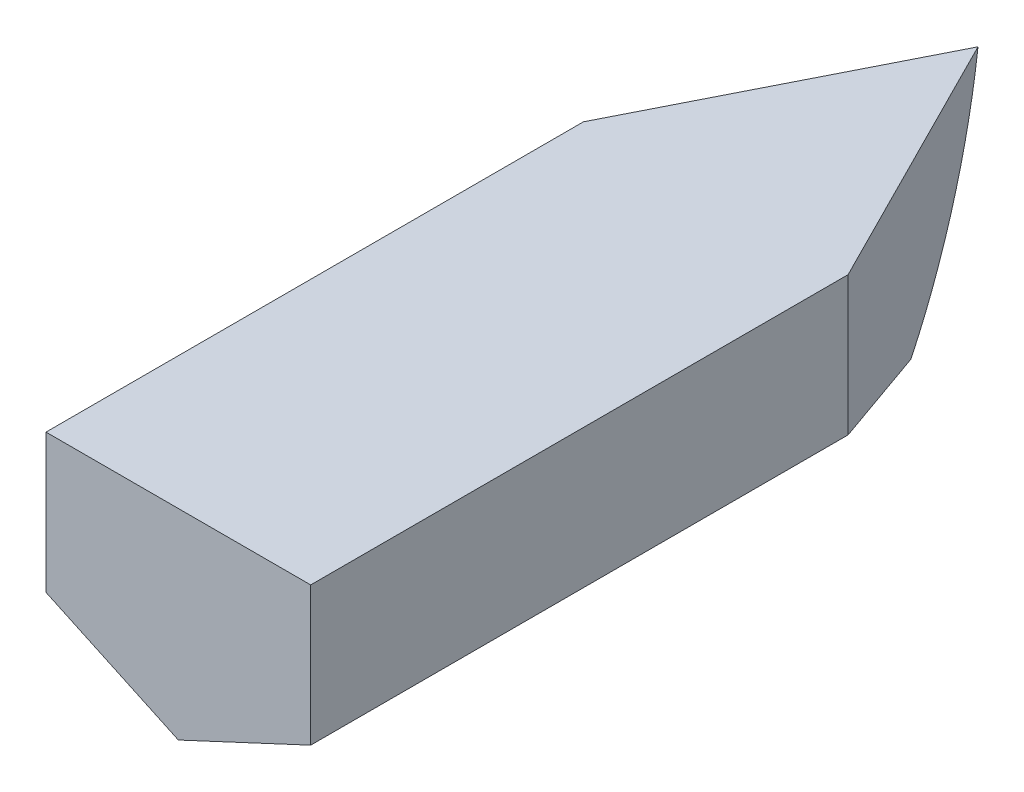
from build123d import *

# Parameters (mm, degrees)
TOP_BOW_EXTRUSION_DEPTH              = 56.86004
PORT_STARBOARD_CUT_DEPTH             = 38.529378828
PORT_STARBOARD_CUT_DEPTH_BACK        = 38.529527124
FORE_AFT_BOW_WRAPUP_EXTRUSTION_REACH = 76.36
SCALE_2_SCALE                        = 2
SHELL2_T                             = 2.54


with BuildPart() as part:
    # Cross-Section C Sketch → Fore-Aft Loft section 0
    with BuildSketch(Plane.XY.offset(76.2)):
        Polygon((-0.000593186, -30.406404979), (37.528192355, -12.906444879), (37.528192355, 26.453635249), (-37.529378728, 26.453635249), (-37.529378728, -12.906444879), align=None)
    # Cross-Section B Sketch → Fore-Aft Loft section 1
    with BuildSketch(Plane.XY):
        Polygon((-0.000593186, -30.406404979), (37.528192355, -12.906444879), (37.528192355, 26.453635249), (-37.529378728, 26.453635249), (-37.529378728, -12.906444879), align=None)
    # Cross-Section A Sketch → Fore-Aft Loft section 2
    with BuildSketch(Plane(origin=(0, 0, -76.2), x_dir=(-1, 0, 0), z_dir=(0, 0, -1))):
        Polygon((-0.000593186, -30.406404979), (37.528192355, -12.906444879), (37.528192355, 26.453635249), (-37.529378728, 26.453635249), (-37.529378728, -12.906444879), align=None)
    loft()

    # Top Bow Profile → Top Bow Extrusion (add)
    with BuildSketch(Plane(origin=(0, 26.453635249, 0), x_dir=(1, 0, 0), z_dir=(0, 1, 0))):
        Polygon((37.529378728, 76.2), (0, 150.560276873), (-37.528192355, 76.2), align=None)
    extrude(amount=-TOP_BOW_EXTRUSION_DEPTH)

    # Port-Starboard Profile → Port-Starboard Cut (cut, two sides)
    with BuildSketch(Plane(origin=(0, 0, 0), x_dir=(0, 0, -1), z_dir=(1, 0, 0))) as port_starboard_cut_sk:
        with BuildLine():
            ThreePointArc((76.2, -30.406404979), (122.925878209, -14.460087823), (150.560276873, 26.453635249))
            Line((150.560276873, 26.453635249), (150.560276873, -30.406404979))
            Line((150.560276873, -30.406404979), (76.2, -30.406404979))
        make_face()
    extrude(amount=PORT_STARBOARD_CUT_DEPTH, mode=Mode.SUBTRACT)
    extrude(port_starboard_cut_sk.sketch, amount=-PORT_STARBOARD_CUT_DEPTH_BACK, mode=Mode.SUBTRACT)

    # Fore-Aft Bow Construction Sketch → Fore-aft bow wrapup extrustion (cut, up to next)
    with BuildSketch(Plane.XY.offset(-76.2), mode=Mode.PRIVATE) as fore_aft_bow_wrapup_extrustion_sk1:
        Polygon((0.000593186, -30.406404979), (37.529378728, -30.406404979), (37.529378728, -12.906444879), align=None)
    fore_aft_bow_wrapup_extrustion_tool1 = extrude(fore_aft_bow_wrapup_extrustion_sk1.sketch, amount=-FORE_AFT_BOW_WRAPUP_EXTRUSTION_REACH, mode=Mode.PRIVATE) & part.part
    add(fore_aft_bow_wrapup_extrustion_tool1.solids().sort_by_distance((25.019784, -24.573085, -76.2))[0], mode=Mode.SUBTRACT)
    # Fore-Aft Bow Construction Sketch → Fore-aft bow wrapup extrustion (cut, up to next)
    with BuildSketch(Plane.XY.offset(-76.2), mode=Mode.PRIVATE) as fore_aft_bow_wrapup_extrustion_sk2:
        Polygon((-37.528192355, -30.406404979), (0.000593186, -30.406404979), (-37.528192355, -12.906444879), align=None)
    fore_aft_bow_wrapup_extrustion_tool2 = extrude(fore_aft_bow_wrapup_extrustion_sk2.sketch, amount=-FORE_AFT_BOW_WRAPUP_EXTRUSTION_REACH, mode=Mode.PRIVATE) & part.part
    add(fore_aft_bow_wrapup_extrustion_tool2.solids().sort_by_distance((-25.018597, -24.573085, -76.2))[0], mode=Mode.SUBTRACT)


with BuildPart() as part_1:
    # Scale 2: scaled about (-0.000240035, 2.235376986, -18.845056047)
    add(part.part.scale(SCALE_2_SCALE).moved(Location((0.000240035, -2.235376986, 18.845056047))))

    # Shell2 (no face opened: a closed hollow body)
    add(offset(amount=-SHELL2_T, mode=Mode.PRIVATE), mode=Mode.SUBTRACT)


solid = part_1.part
